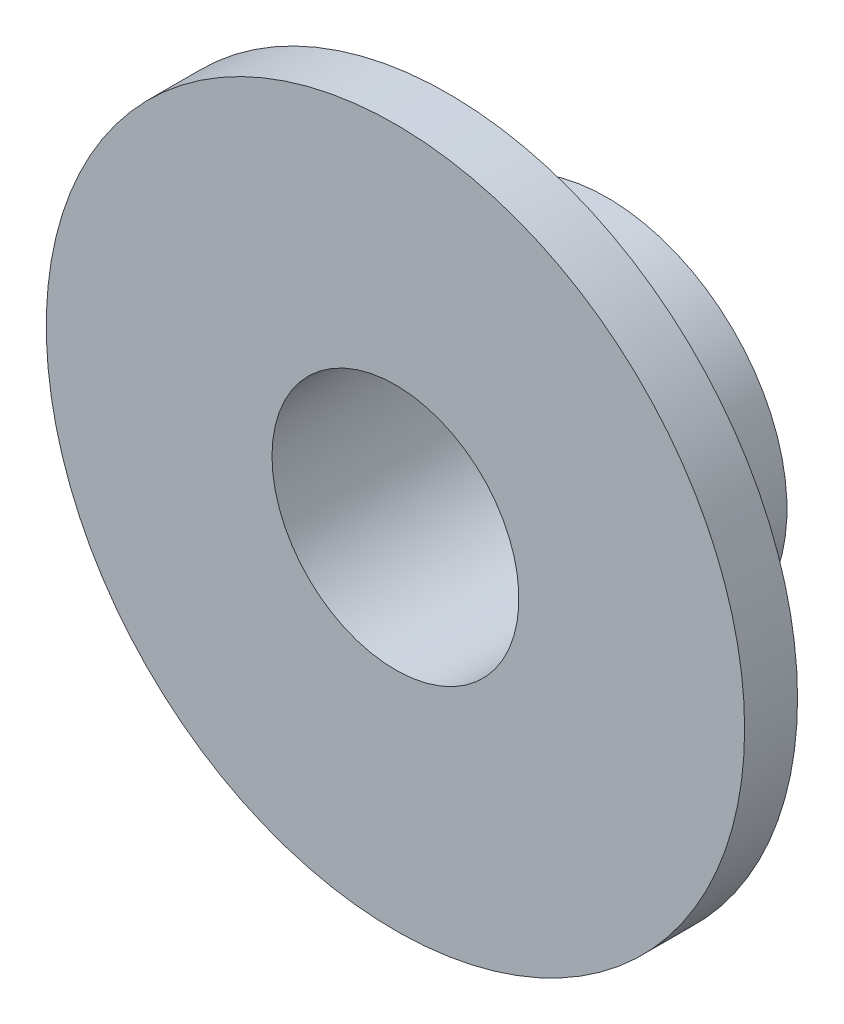
from build123d import *

# Parameters (mm, degrees)
SKETCH1_R           = 9.9
BOSS_EXTRUDE1_DEPTH = 1.5
SKETCH2_R           = 5.1
BOSS_EXTRUDE2_DEPTH = 4.5
SKETCH3_R           = 3.5
CUT_EXTRUDE1_DEPTH  = 7


with BuildPart() as part:
    # Sketch1 → Boss-Extrude1 (new body)
    with BuildSketch(Plane.XY.offset(28.963778517)):
        with Locations((13.758033718, 17.384066602)):
            Circle(SKETCH1_R)
    extrude(amount=BOSS_EXTRUDE1_DEPTH)

    # Sketch2 → Boss-Extrude2 (add)
    with BuildSketch(Plane(origin=(0, 0, 28.963778517), x_dir=(-1, 0, 0), z_dir=(0, 0, -1))):
        with Locations((-13.758033718, 17.384066602)):
            Circle(SKETCH2_R)
    extrude(amount=BOSS_EXTRUDE2_DEPTH)

    # Sketch3 → Cut-Extrude1 (cut, through all)
    with BuildSketch(Plane(origin=(0, 0, 24.463778517), x_dir=(-1, 0, 0), z_dir=(0, 0, -1))):
        with Locations((-13.758033718, 17.384066602)):
            Circle(SKETCH3_R)
    extrude(amount=-CUT_EXTRUDE1_DEPTH, mode=Mode.SUBTRACT)


solid = part.part
